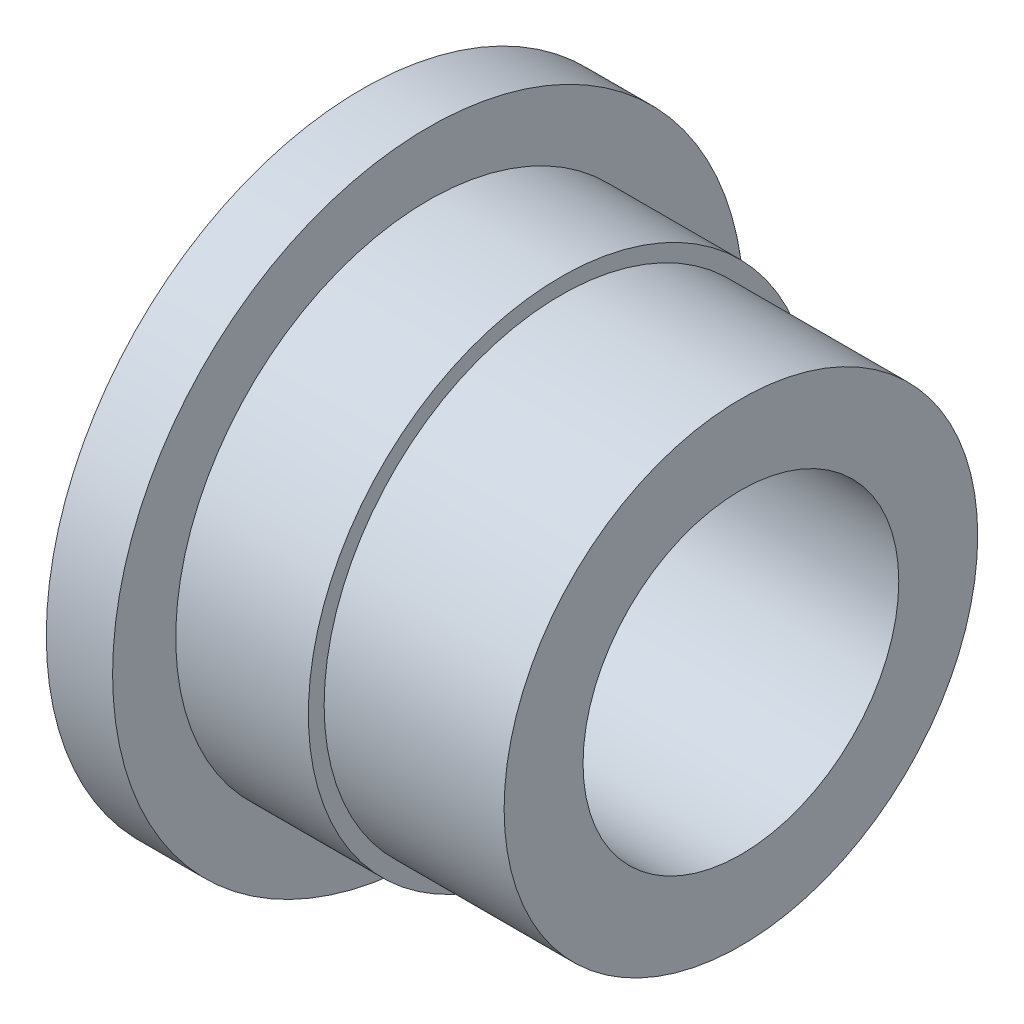
from build123d import *


with BuildPart() as part:
    # Sketch1 → Base-Revolve (revolve)
    with BuildSketch(Plane.XY):
        Polygon((0, 5), (0, 7.5), (-5.7, 7.5), (-5.7, 8), (-9.9, 8), (-9.9, 10), (-12, 10), (-12, 5), align=None)
    revolve(axis=Axis((0, 0, 0), (-1, 0, 0)))


solid = part.part
